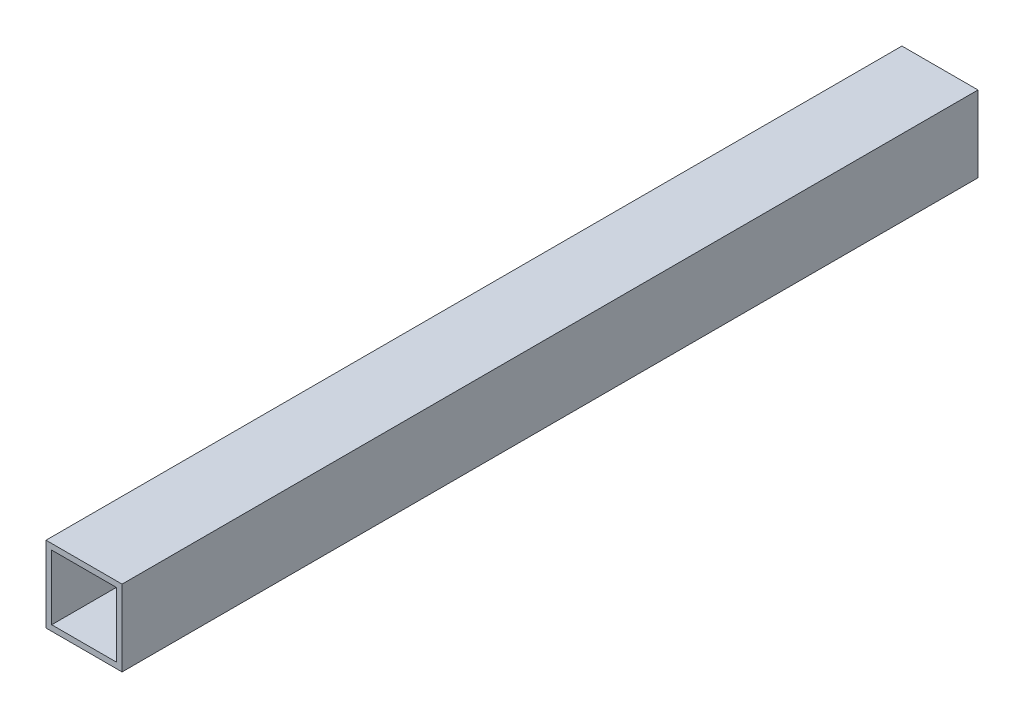
from build123d import *

# Parameters (mm, degrees)
CROQUIS1_W              = 40
CROQUIS1_H              = 40
CROQUIS1_W_2            = 34
CROQUIS1_H_2            = 34
SALIENTE_EXTRUIR1_DEPTH = 450


with BuildPart() as part:
    # Croquis1 → Saliente-Extruir1 (new body)
    with BuildSketch(Plane.XY):
        Rectangle(CROQUIS1_W, CROQUIS1_H)
        Rectangle(CROQUIS1_W_2, CROQUIS1_H_2, mode=Mode.SUBTRACT)
    extrude(amount=SALIENTE_EXTRUIR1_DEPTH)


solid = part.part
